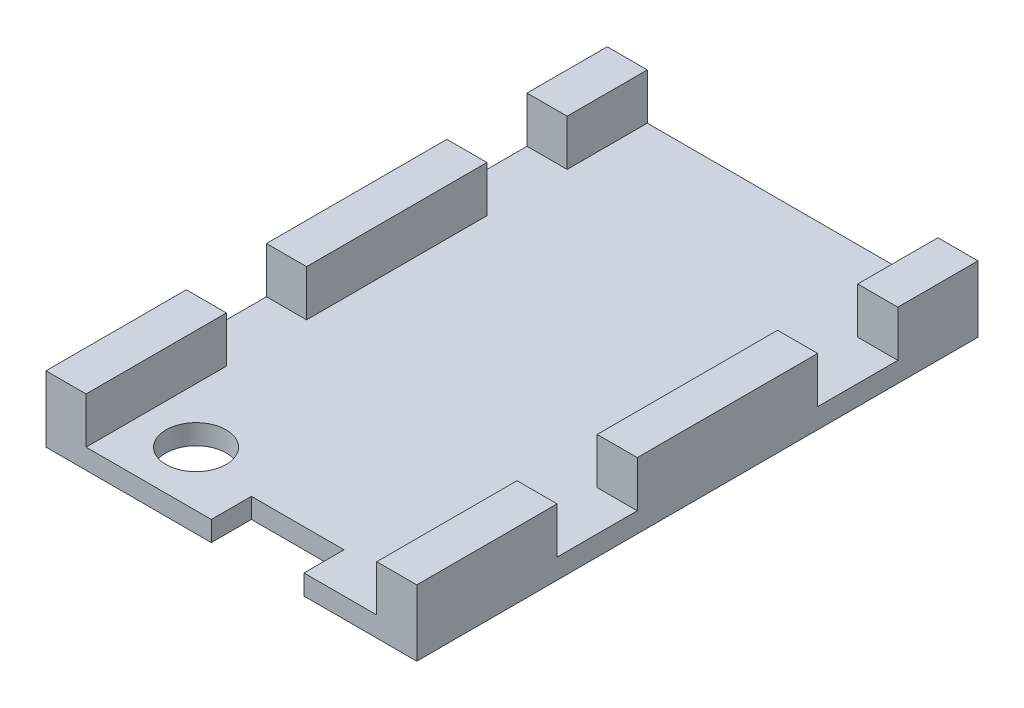
from build123d import *

# Parameters (mm, degrees)
MAIN_BOARD_OUTLINE_W = 18.5
MAIN_BOARD_OUTLINE_H = 28
SIDE1_DEPTH          = 1
SKETCH2_W            = 2
SKETCH2_H            = 28
WALLS_DEPTH          = 2.3
SKETCH3_R            = 1.5
SCREW_HOLE_DEPTH     = 2.3
SKETCH4_W            = 4.6228
SKETCH4_H            = 2
SPI_HOLE_DEPTH       = 2.3
SKETCH5_W            = 2
SKETCH5_H            = 4
CUT_EXTRUDE3_DEPTH   = 2.3


with BuildPart() as part:
    # main board outline → side1 (new body)
    with BuildSketch(Plane(origin=(0, 0, 0), x_dir=(1, 0, 0), z_dir=(0, 1, 0))):
        with Locations((-19.997374583, 0.651042113)):
            Rectangle(MAIN_BOARD_OUTLINE_W, MAIN_BOARD_OUTLINE_H)
    extrude(amount=SIDE1_DEPTH)

    # Sketch2 → walls (add)
    with BuildSketch(Plane(origin=(0, 1, 0), x_dir=(1, 0, 0), z_dir=(0, 1, 0))):
        with Locations((-28.247374583, 0.651042113)):
            Rectangle(SKETCH2_W, SKETCH2_H)
        with Locations((-11.747374583, 0.651042113)):
            Rectangle(SKETCH2_W, SKETCH2_H)
    extrude(amount=WALLS_DEPTH)

    # Sketch3 → screw hole (cut)
    with BuildSketch(Plane(origin=(0, 0, 0), x_dir=(-1, 0, 0), z_dir=(0, -1, 0))):
        with Locations((24.504374583, -10.605757887)):
            Circle(SKETCH3_R)
    extrude(amount=-SCREW_HOLE_DEPTH, mode=Mode.SUBTRACT)

    # Sketch4 → spi hole (cut)
    with BuildSketch(Plane(origin=(0, 0, 0), x_dir=(-1, 0, 0), z_dir=(0, -1, 0))):
        with Locations((18.687974583, -12.348957887)):
            Rectangle(SKETCH4_W, SKETCH4_H)
    extrude(amount=-SPI_HOLE_DEPTH, mode=Mode.SUBTRACT)

    # Sketch5 → Cut-Extrude3 (cut)
    with BuildSketch(Plane(origin=(0, 3.3, 0), x_dir=(1, 0, 0), z_dir=(0, 1, 0))):
        with Locations((-28.247374583, 8.651042113)):
            Rectangle(SKETCH5_W, SKETCH5_H)
        with Locations((-28.247374583, -4.348957887)):
            Rectangle(SKETCH5_W, SKETCH5_H)
        with Locations((-11.747374583, 8.651042113)):
            Rectangle(SKETCH5_W, SKETCH5_H)
        with Locations((-11.747374583, -4.348957887)):
            Rectangle(SKETCH5_W, SKETCH5_H)
    extrude(amount=-CUT_EXTRUDE3_DEPTH, mode=Mode.SUBTRACT)


solid = part.part
